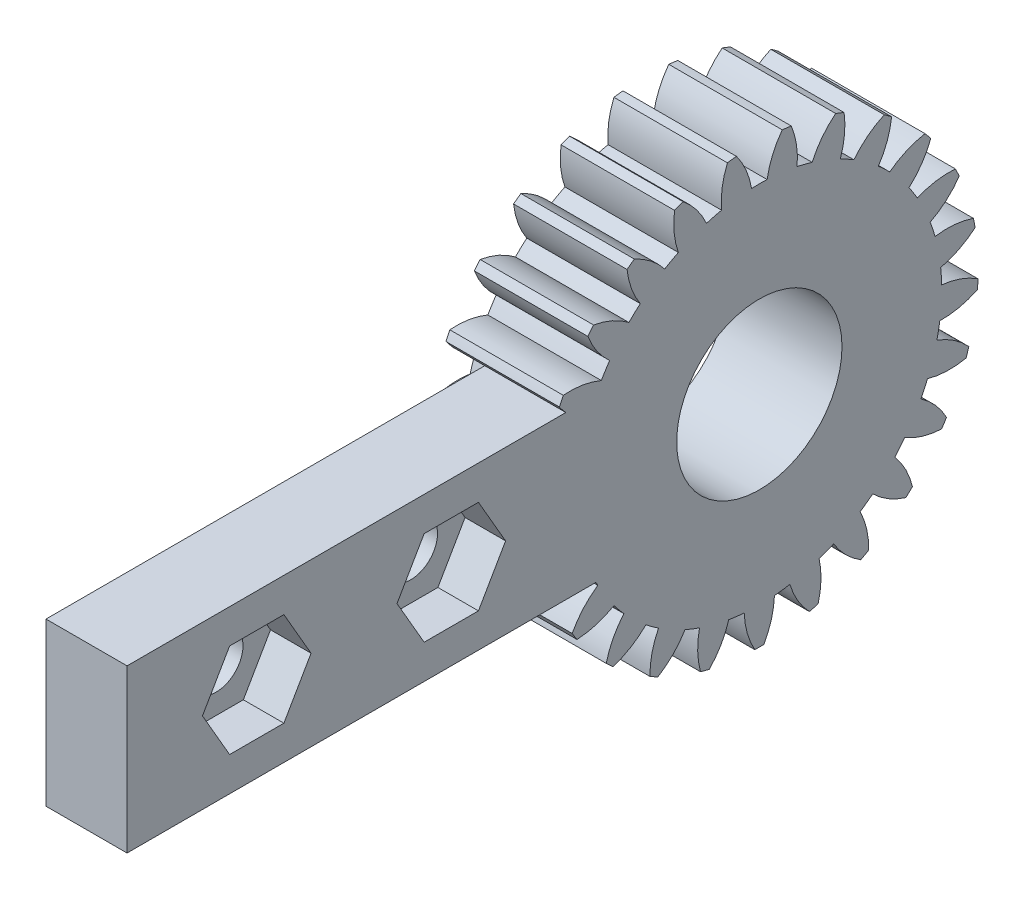
from build123d import *

# Parameters (mm, degrees)
BASPROSKE_W         = 7
BASPROSKE_H         = 13.5
TOOTHCUT_DEPTH      = 21.334699408
TEETHCUTS_COUNT     = 25
TEETHCUTS_ANGLE     = 345.6
BORSKE_R            = 0.4
BORE_DEPTH          = 50.0000508
SKETCH_1_R          = 5.1
CUT_EXTRUDE_1_DEPTH = 10
SKETCH_2_W          = 30
SKETCH_2_H          = 10
SKETCH_2_R          = 1.65
EXTRUDE_2_DEPTH     = 5
CUT_EXTRUDE_2_DEPTH = 2.5


with BuildPart() as part:
    # BasProSke → Base-Revolve (revolve)
    with BuildSketch(Plane(origin=(0, 0, 0), x_dir=(1, 0, 0), z_dir=(0, 1, 0)), mode=Mode.PRIVATE) as base_revolve_sk:
        with Locations((3.5, 6.75)):
            Rectangle(BASPROSKE_W, BASPROSKE_H)
    revolve(base_revolve_sk.sketch.rotate(Axis((-10, 0, 0), (1, 0, 0)), 180), axis=Axis((-10, 0, 0), (1, 0, 0)))

    # TooCutSke → ToothCut (cut, through all)
    with BuildSketch(Plane(origin=(0, 0, 0), x_dir=(0, 0, -1), z_dir=(1, 0, 0))):
        with BuildLine():
            ThreePointArc((0.480087995, 11.238750665), (0, 11.249), (-0.480087995, 11.238750665))
            ThreePointArc((-0.480087995, 11.238750665), (-0.821124963, 12.40220054), (-1.432168974, 13.449361962))
            ThreePointArc((-1.432168974, 13.449361962), (0, 13.5254), (1.432168974, 13.449361962))
            ThreePointArc((1.432168974, 13.449361962), (0.821124963, 12.40220054), (0.480087995, 11.238750665))
        make_face()
    toothcut = extrude(amount=TOOTHCUT_DEPTH, mode=Mode.SUBTRACT)

    # TeethCuts: ToothCut ×25 about axis
    teethcuts_axis = Axis((-10, 0, 0), (1, 0, 0))
    for i in range(1, TEETHCUTS_COUNT):
        add(toothcut.rotate(teethcuts_axis, i * TEETHCUTS_ANGLE / (TEETHCUTS_COUNT - 1)), mode=Mode.SUBTRACT)

    # BorSke → Bore (cut, symmetric)
    with BuildSketch(Plane(origin=(0, 0, 0), x_dir=(0, 0, -1), z_dir=(1, 0, 0))):
        with Locations(Location((0, 0, 0), (0, 0, 180))):
            Circle(BORSKE_R)
    extrude(amount=BORE_DEPTH, both=True, mode=Mode.SUBTRACT)

    # 草图1 → 切除-拉伸1 (cut)
    with BuildSketch(Plane(origin=(7, 0, 0), x_dir=(0, 0, -1), z_dir=(1, 0, 0))):
        Circle(SKETCH_1_R)
    extrude(amount=-CUT_EXTRUDE_1_DEPTH, mode=Mode.SUBTRACT)

    # 草图2 → 凸台-拉伸2 (add)
    with BuildSketch(Plane(origin=(7, 0, 0), x_dir=(0, 0, -1), z_dir=(1, 0, 0))):
        with Locations((-24, 0)):
            Rectangle(SKETCH_2_W, SKETCH_2_H)
        with Locations((-31, 0)):
            Circle(SKETCH_2_R, mode=Mode.SUBTRACT)
        with Locations((-19, 0)):
            Circle(SKETCH_2_R, mode=Mode.SUBTRACT)
    extrude(amount=-EXTRUDE_2_DEPTH)

    # 草图3 → 切除-拉伸2 (cut)
    with BuildSketch(Plane(origin=(7, 0, 0), x_dir=(0, 0, -1), z_dir=(1, 0, 0))):
        Polygon((-27.651368439, 0), (-29.325684219, 2.9), (-32.674315781, 2.9), (-34.348631561, 0), (-32.674315781, -2.9), (-29.325684219, -2.9), align=None)
        Polygon((-15.651368439, 0), (-17.325684219, 2.9), (-20.674315781, 2.9), (-22.348631561, 0), (-20.674315781, -2.9), (-17.325684219, -2.9), align=None)
    extrude(amount=-CUT_EXTRUDE_2_DEPTH, mode=Mode.SUBTRACT)


solid = part.part
